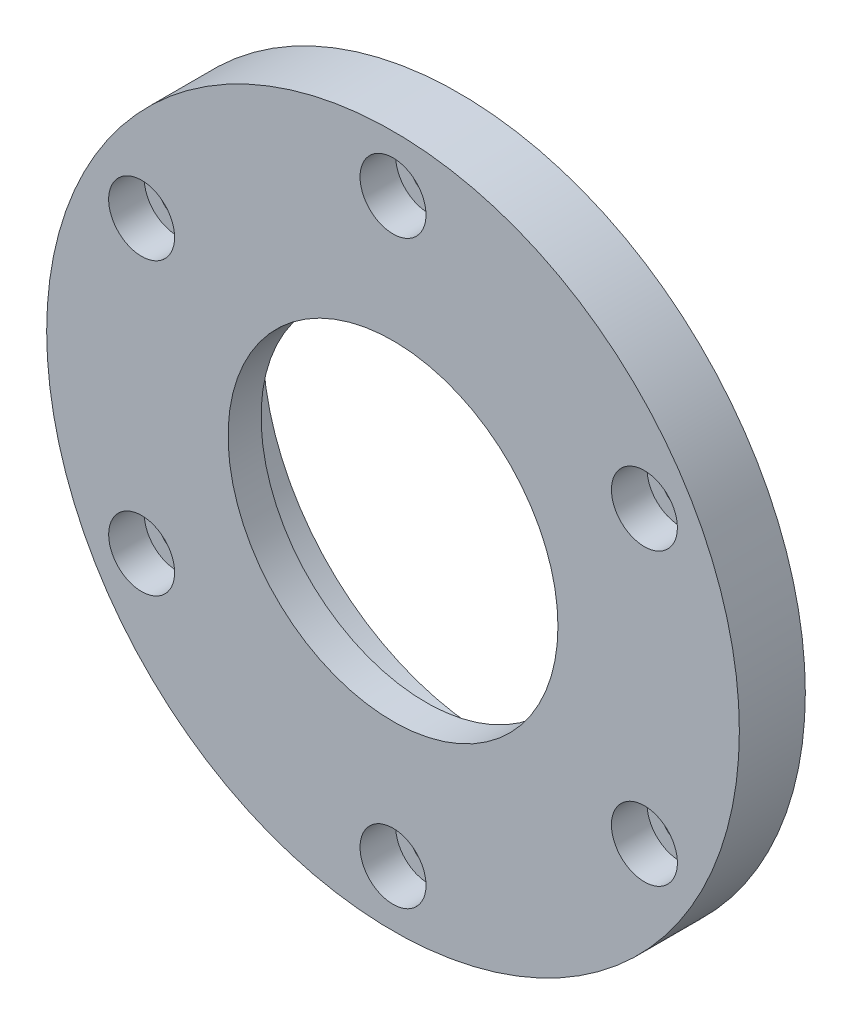
from build123d import *

# Parameters (mm, degrees)
SKIZZE1_R                                            = 52.5
AUFSATZ_LINEAR_AUSTRAGEN1_DEPTH                      = 10
SKIZZE2_R                                            = 40
AUFSATZ_LINEAR_AUSTRAGEN3_DEPTH                      = 5
SKIZZE5_OUTSIDE_W                                    = 136.85
SKIZZE5_OUTSIDE_H                                    = 136.85
SKIZZE5_OUTSIDE_R                                    = 35
SCHNITT_LINEAR_AUSTRAGEN1_DEPTH                      = 5
SKIZZE6_R                                            = 38
AUFSATZ_LINEAR_AUSTRAGEN4_DEPTH                      = 5
SCHNITT_LINEAR_START                                 = -5
SKIZZE7_R                                            = 34.75
SCHNITT_LINEAR_AUSTRAGEN2_DEPTH                      = 10
SKIZZE10_R                                           = 25
SCHNITT_LINEAR_AUSTRAGEN4_DEPTH                      = 10
STIRNSENKUNG_F_R_M5_ZYLINDERSCHRAUBE_MIT_D           = 5.5
STIRNSENKUNG_F_R_M5_ZYLINDERSCHRAUBE_MIT_CBORE_D     = 10
STIRNSENKUNG_F_R_M5_ZYLINDERSCHRAUBE_MIT_CBORE_DEPTH = 5.4
KREISMUSTER4_COUNT                                   = 6
SKIZZE16_R                                           = 39
SKIZZE16_R_2                                         = 38
O_RING_NUT_DEPTH                                     = 1
SKIZZE17_R                                           = 40.85
SKIZZE17_R_2                                         = 38
SCHNITT_LINEAR_AUSTRAGEN5_DEPTH                      = 1.45
VERRUNDUNG1_R                                        = 0.3


with BuildPart() as part:
    # Skizze1 → Aufsatz-Linear austragen1 (new body)
    with BuildSketch(Plane.XY):
        Circle(SKIZZE1_R)
    extrude(amount=AUFSATZ_LINEAR_AUSTRAGEN1_DEPTH)

    # Skizze2 → Aufsatz-Linear austragen3 (add)
    with BuildSketch(Plane.XY):
        Circle(SKIZZE2_R)
    extrude(amount=-AUFSATZ_LINEAR_AUSTRAGEN3_DEPTH)

    # Skizze5 outside → Schnitt-Linear austragen1 (cut)
    with BuildSketch(Plane.XY):
        Rectangle(SKIZZE5_OUTSIDE_W, SKIZZE5_OUTSIDE_H)
        Circle(SKIZZE5_OUTSIDE_R, mode=Mode.SUBTRACT)
    extrude(amount=-SCHNITT_LINEAR_AUSTRAGEN1_DEPTH, mode=Mode.SUBTRACT)

    # Skizze6 → Aufsatz-Linear austragen4 (add)
    with BuildSketch(Plane.XY):
        Circle(SKIZZE6_R)
    extrude(amount=-AUFSATZ_LINEAR_AUSTRAGEN4_DEPTH)

    # Skizze7 → Schnitt-Linear austragen2 (cut)
    with BuildSketch(Plane.XY.offset(SCHNITT_LINEAR_START)):
        Circle(SKIZZE7_R)
    extrude(amount=SCHNITT_LINEAR_AUSTRAGEN2_DEPTH, mode=Mode.SUBTRACT)

    # Skizze10 → Schnitt-Linear austragen4 (cut)
    with BuildSketch(Plane.XY):
        Circle(SKIZZE10_R)
    extrude(amount=SCHNITT_LINEAR_AUSTRAGEN4_DEPTH, mode=Mode.SUBTRACT)

    # Stirnsenkung f_r M5 Zylinderschraube mit (through all)
    with Locations(Plane.XY.offset(10)):
        with Locations((0, -44)):
            stirnsenkung_f_r_m5_zylinderschraube_mit = CounterBoreHole(STIRNSENKUNG_F_R_M5_ZYLINDERSCHRAUBE_MIT_D / 2, STIRNSENKUNG_F_R_M5_ZYLINDERSCHRAUBE_MIT_CBORE_D / 2, STIRNSENKUNG_F_R_M5_ZYLINDERSCHRAUBE_MIT_CBORE_DEPTH)

    # Kreismuster4: Stirnsenkung f_r M5 Zylinderschraube mit ×6 about axis
    kreismuster4_axis = Axis((0, 0, 0), (0, 0, 1))
    for i in range(1, KREISMUSTER4_COUNT):
        add(stirnsenkung_f_r_m5_zylinderschraube_mit.rotate(kreismuster4_axis, i * 360 / KREISMUSTER4_COUNT), mode=Mode.SUBTRACT)

    # Skizze16 → o ring nut (cut)
    with BuildSketch(Plane(origin=(0, 0, 0), x_dir=(-1, 0, 0), z_dir=(0, 0, -1))):
        Circle(SKIZZE16_R)
        with Locations(Location((0, 0, 0), (0, 0, 180))):  # turned: the seam where the file's is
            Circle(SKIZZE16_R_2, mode=Mode.SUBTRACT)
    extrude(amount=-O_RING_NUT_DEPTH, mode=Mode.SUBTRACT)

    # Skizze17 → Schnitt-Linear austragen5 (cut)
    with BuildSketch(Plane(origin=(0, 0, 0), x_dir=(-1, 0, 0), z_dir=(0, 0, -1))):
        Circle(SKIZZE17_R)
        with Locations(Location((0, 0, 0), (0, 0, 180))):  # turned: the seam where the file's is
            Circle(SKIZZE17_R_2, mode=Mode.SUBTRACT)
    extrude(amount=-SCHNITT_LINEAR_AUSTRAGEN5_DEPTH, mode=Mode.SUBTRACT)

    # Verrundung1
    verrundung1_edges = [part.edges().sort_by_distance(p)[0] for p in [
        (40.85, 0, 1.45),
        (-38, 0, 1.45),
    ]]
    fillet(verrundung1_edges, radius=VERRUNDUNG1_R)


solid = part.part
